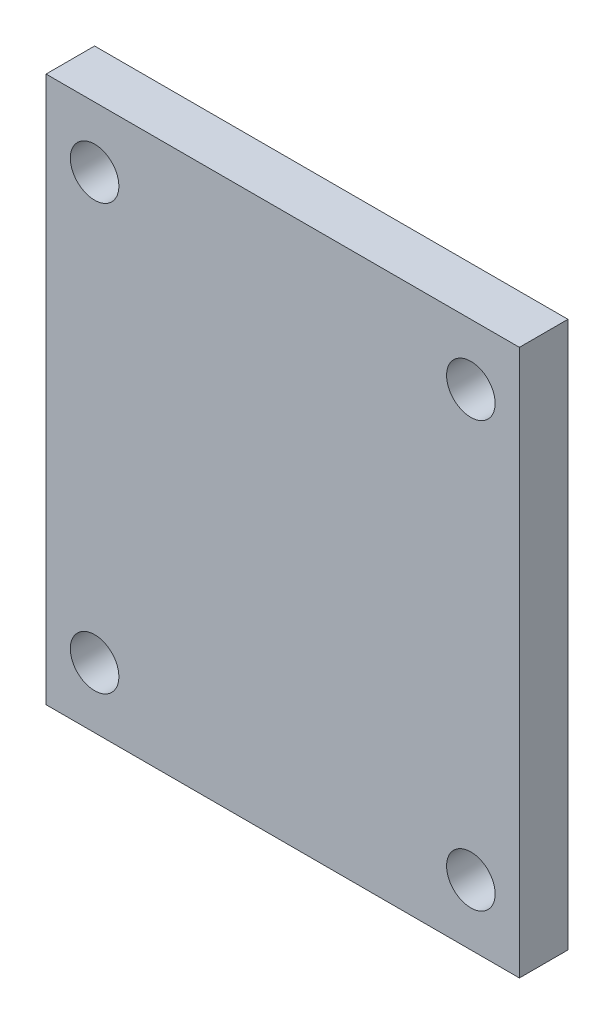
from build123d import *

# Parameters (mm, degrees)
SKETCH1_W           = 39
SKETCH1_H           = 45
SKETCH1_R           = 2
BOSS_EXTRUDE1_DEPTH = 4


with BuildPart() as part:
    # Sketch1 → Boss-Extrude1 (new body)
    with BuildSketch(Plane.XY):
        with Locations((-0.383589858, -0.095897464)):
            Rectangle(SKETCH1_W, SKETCH1_H)
        with Locations((-15.883589858, -17.595897464)):
            Circle(SKETCH1_R, mode=Mode.SUBTRACT)
        with Locations((15.116410142, -17.595897464)):
            Circle(SKETCH1_R, mode=Mode.SUBTRACT)
        with Locations((15.116410142, 17.404102536)):
            Circle(SKETCH1_R, mode=Mode.SUBTRACT)
        with Locations((-15.883589858, 17.404102536)):
            Circle(SKETCH1_R, mode=Mode.SUBTRACT)
    extrude(amount=BOSS_EXTRUDE1_DEPTH)


solid = part.part
